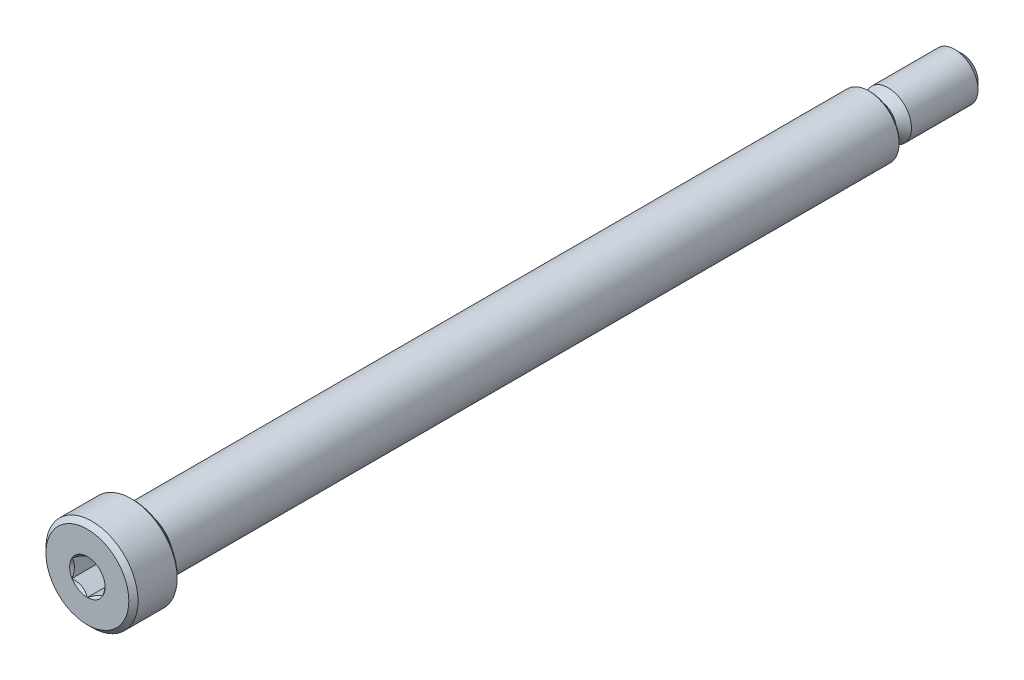
from build123d import *

# Parameters (mm, degrees)
CUT_EXTRUDE1_DEPTH = 3.095625
SKETCH5_R          = 1.833087105
CUT_EXTRUDE2_DEPTH = 3.095625
CUT_EXTRUDE2_DRAFT = -45


with BuildPart() as part:
    # Sketch3 → Revolve1 (revolve)
    with BuildSketch(Plane(origin=(0, 0, 0), x_dir=(0, 0, -1), z_dir=(1, 0, 0))):
        with BuildLine():
            Line((-45.24375, 0), (-45.24375, 4.28625))
            Line((-45.24375, 4.28625), (-44.7675, 4.7625))
            Line((-44.7675, 4.7625), (-40.719375, 4.7625))
            Line((-40.719375, 4.7625), (-40.48125, 4.524375))
            Line((-40.48125, 4.524375), (-40.48125, 3.09768875))
            ThreePointArc((-40.48125, 3.09768875), (-40.446795872, 3.014509128), (-40.36361625, 2.980055))
            Line((-40.36361625, 2.980055), (-39.579761667, 2.980055))
            Line((-39.579761667, 2.980055), (-39.422916667, 3.1369))
            Line((-39.422916667, 3.1369), (35.561905, 3.1369))
            Line((35.561905, 3.1369), (35.71875, 2.980055))
            Line((35.71875, 2.980055), (35.71875, 2.016125))
            ThreePointArc((35.71875, 2.016125), (35.834991996, 1.735491996), (36.115625, 1.61925))
            Line((36.115625, 1.61925), (36.777083333, 1.61925))
            Line((36.777083333, 1.61925), (37.570833333, 2.413))
            Line((37.570833333, 2.413), (44.45, 2.413))
            Line((44.45, 2.413), (45.24375, 1.61925))
            Line((45.24375, 1.61925), (45.24375, 0))
            Line((45.24375, 0), (-45.24375, 0))
        make_face()
    revolve(axis=Axis((0, 0, 45.24375), (0, 0, -1)))

    # Sketch4 → Cut-Extrude1 (cut)
    with BuildSketch(Plane.XY.offset(45.24375)):
        Polygon((-1.5875, -0.916543552), (0, -1.833087105), (1.5875, -0.916543552), (1.5875, 0.916543552), (0, 1.833087105), (-1.5875, 0.916543552), align=None)
    extrude(amount=-CUT_EXTRUDE1_DEPTH, mode=Mode.SUBTRACT)


with BuildPart() as cut_extrude2_tool:
    # Sketch5 → Cut-Extrude2 (with draft: the straight prism first)
    with BuildSketch(Plane.XY.offset(45.24375)):
        Circle(SKETCH5_R)
    extrude(amount=-CUT_EXTRUDE2_DEPTH)
    # Cut-Extrude2: the draft: its side faces are tilted about the plane it starts from
    cut_extrude2_sides = [cut_extrude2_tool.faces().sort_by_distance(p)[0] for p in [
        (-1.833087105, 0, 43.6959375),
    ]]
    draft(cut_extrude2_sides, Plane.XY.offset(45.24375), CUT_EXTRUDE2_DRAFT)


with BuildPart() as part_1:
    add(part.part)

    # Cut-Extrude2: cut by cut_extrude2_tool
    add(cut_extrude2_tool.part, mode=Mode.SUBTRACT)


solid = part_1.part
